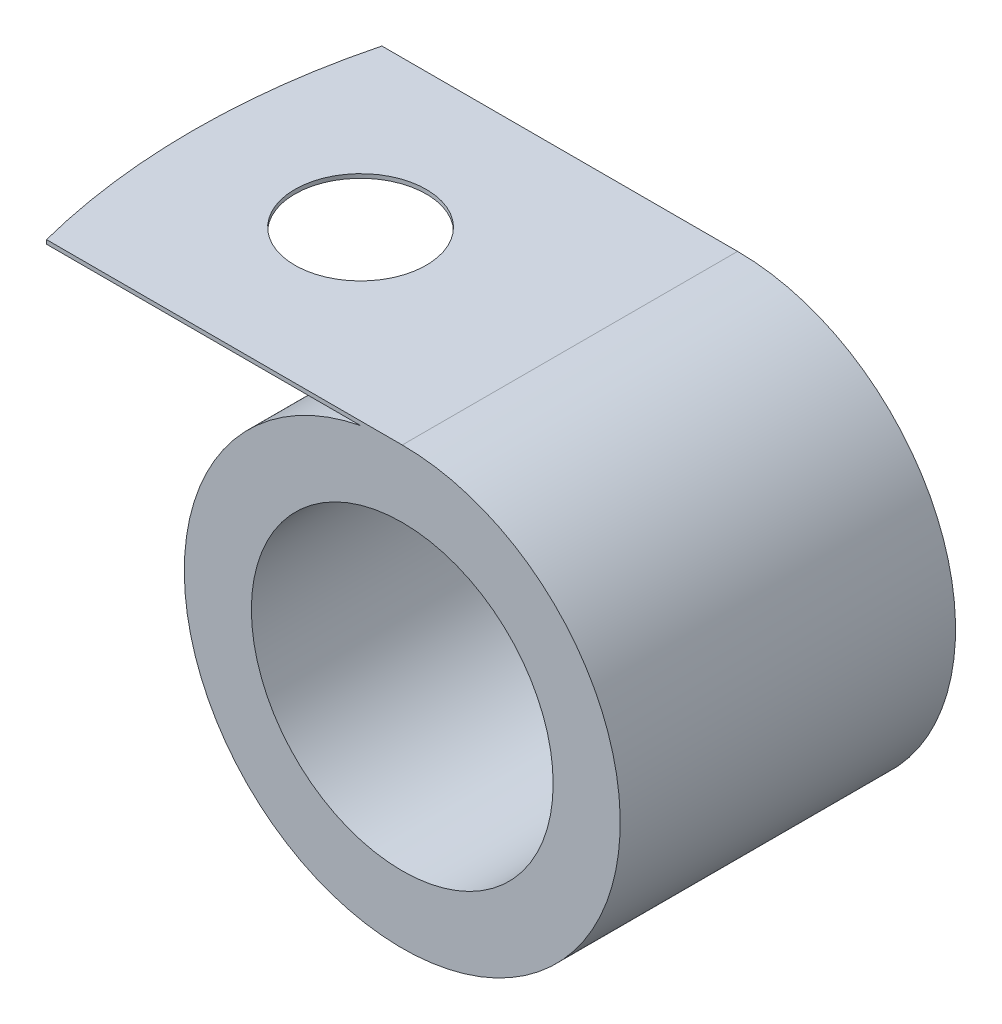
from build123d import *

# Parameters (mm, degrees)
SKETCH1_R           = 5.715
BOSS_EXTRUDE1_DEPTH = 6.35
CUT_EXTRUDE1_REACH  = 18.51
SKETCH2_R           = 2.4892


with BuildPart() as part:
    # Sketch1 → Boss-Extrude1 (new body, symmetric)
    with BuildSketch(Plane.XY):
        with BuildLine():
            Line((0, 8.255), (-14.278891459, 8.255))
            Line((-14.278891459, 8.255), (-14.278891459, 8.1026))
            Line((-14.278891459, 8.1026), (-1.578891459, 8.1026))
            ThreePointArc((-1.578891459, 8.1026), (0.793114746, -8.216811669), (0, 8.255))
        make_face()
        Circle(SKETCH1_R, mode=Mode.SUBTRACT)
    extrude(amount=BOSS_EXTRUDE1_DEPTH, both=True)

    # Sketch2 → Cut-Extrude1 (cut, up to next)
    with BuildSketch(Plane(origin=(0, 8.255, 0), x_dir=(1, 0, 0), z_dir=(0, 1, 0)), mode=Mode.PRIVATE) as cut_extrude1_sk1:
        with Locations((-7.928891459, 0)):
            Circle(SKETCH2_R)
    cut_extrude1_tool1 = extrude(cut_extrude1_sk1.sketch, amount=-CUT_EXTRUDE1_REACH, mode=Mode.PRIVATE) & part.part
    add(cut_extrude1_tool1.solids().sort_by_distance((-7.928891, 8.255, 0))[0], mode=Mode.SUBTRACT)
    # Sketch2 → Cut-Extrude1 (cut, up to next)
    with BuildSketch(Plane(origin=(0, 8.255, 0), x_dir=(1, 0, 0), z_dir=(0, 1, 0)), mode=Mode.PRIVATE) as cut_extrude1_sk2:
        with BuildLine():
            ThreePointArc((-14.278891459, 0), (-14.076445744, 3.200509029), (-13.472335708, 6.35))
            Line((-13.472335708, 6.35), (-14.278891459, 6.35))
            Line((-14.278891459, 6.35), (-14.278891459, 0))
        make_face()
    cut_extrude1_tool2 = extrude(cut_extrude1_sk2.sketch, amount=-CUT_EXTRUDE1_REACH, mode=Mode.PRIVATE) & part.part
    add(cut_extrude1_tool2.solids().sort_by_distance((-14.037598, 8.255, -4.767585))[0], mode=Mode.SUBTRACT)
    # Sketch2 → Cut-Extrude1 (cut, up to next)
    with BuildSketch(Plane(origin=(0, 8.255, 0), x_dir=(1, 0, 0), z_dir=(0, 1, 0)), mode=Mode.PRIVATE) as cut_extrude1_sk3:
        with BuildLine():
            ThreePointArc((-13.472335708, -6.35), (-14.076445744, -3.200509029), (-14.278891459, 0))
            Line((-14.278891459, 0), (-14.278891459, -6.35))
            Line((-14.278891459, -6.35), (-13.472335708, -6.35))
        make_face()
    cut_extrude1_tool3 = extrude(cut_extrude1_sk3.sketch, amount=-CUT_EXTRUDE1_REACH, mode=Mode.PRIVATE) & part.part
    add(cut_extrude1_tool3.solids().sort_by_distance((-14.037598, 8.255, 4.767585))[0], mode=Mode.SUBTRACT)


solid = part.part
